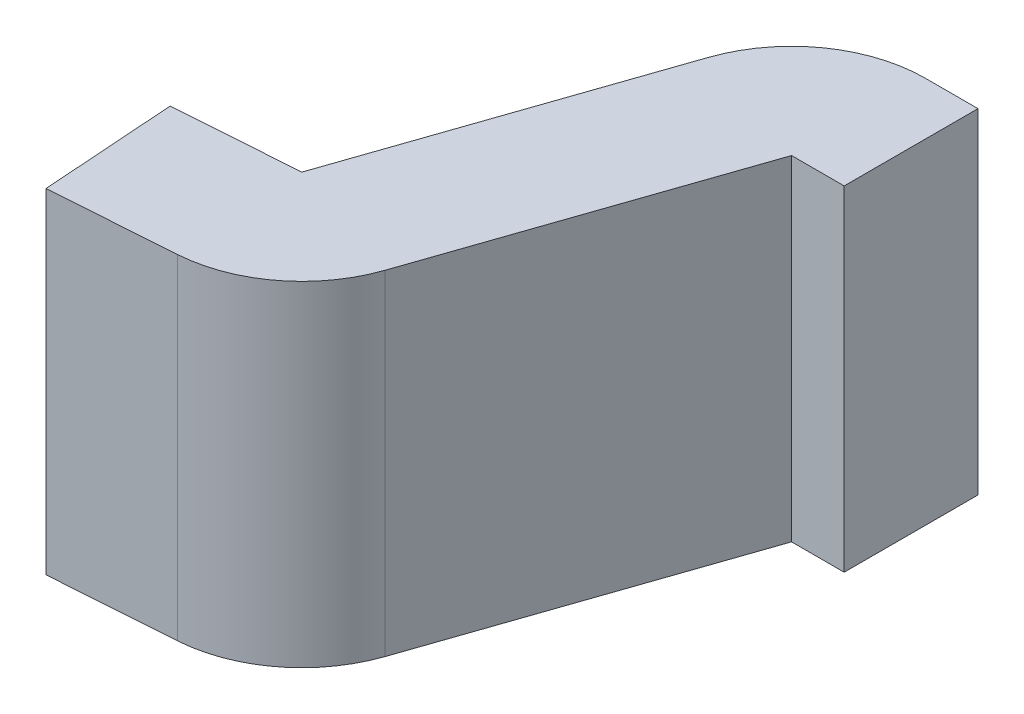
from build123d import *

# Parameters (mm, degrees)
BOSS_EXTRUDE1_DEPTH = 0.25


with BuildPart() as part:
    # Sketch2 → Boss-Extrude1 (new, symmetric)
    with BuildSketch(Plane(origin=(0, 0, 0), x_dir=(1, 0, 0), z_dir=(0, 1, 0))):
        with BuildLine():
            Line((0.006975647, -0.099756405), (0.190884751, -0.086896228))
            ThreePointArc((0.190884751, -0.086896228), (0.298756023, -0.046000133), (0.366094789, 0.047670525))
            Line((0.366094789, 0.047670525), (0.521396168, 0.5))
            Line((0.521396168, 0.5), (0.6, 0.5))
            Line((0.6, 0.5), (0.6, 0.7))
            Line((0.6, 0.7), (0.521396168, 0.7))
            ThreePointArc((0.521396168, 0.7), (0.405183457, 0.662771637), (0.332234836, 0.564946057))
            Line((0.332234836, 0.564946057), (0.176933457, 0.112616582))
            Line((0.176933457, 0.112616582), (-0.006975647, 0.099756405))
            Line((-0.006975647, 0.099756405), (0.006975647, -0.099756405))
        make_face()
    extrude(amount=BOSS_EXTRUDE1_DEPTH, both=True)


solid = part.part
